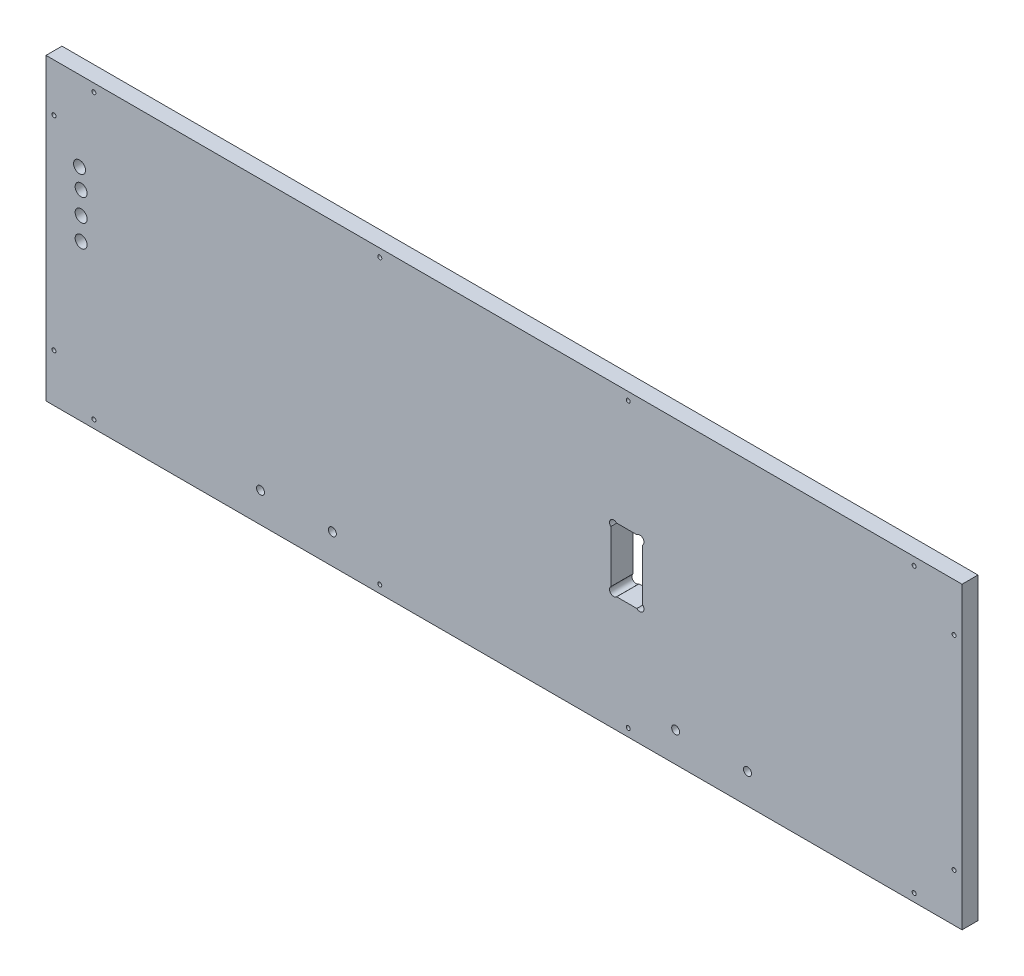
from build123d import *

# Parameters (mm, degrees)
SKETCH2_W          = 728.6625
SKETCH2_H          = 238.125
EXTRUDE1_DEPTH     = 17.78
SKETCH3_R          = 1.5875
SKETCH3_R_2        = 3.175
SKETCH3_W          = 25.4
SKETCH3_H          = 50.8
CUT_EXTRUDE1_DEPTH = 17.78
SKETCH6_R          = 3.302
CUT_EXTRUDE4_DEPTH = 17.78
SKETCH4_W          = 169.8625
SKETCH4_H          = 8.255
CUT_EXTRUDE2_DEPTH = 3.175
CUT_EXTRUDE3_DEPTH = 5.08
SKETCH7_R          = 3.302
CUT_EXTRUDE5_DEPTH = 5.08
SKETCH8_R          = 4.7625
CUT_EXTRUDE6_DEPTH = 17.78


with BuildPart() as part:
    # Sketch2 → Extrude1 (new body)
    with BuildSketch(Plane.XY):
        with Locations((-5376.06875, 779.4625)):
            Rectangle(SKETCH2_W, SKETCH2_H)
    extrude(amount=-EXTRUDE1_DEPTH)

    # Sketch3 → Cut-Extrude1 (cut)
    with BuildSketch(Plane.XY):
        with Locations((-5702.3, 892.175)):
            Circle(SKETCH3_R)
        with Locations((-5734.05, 860.425)):
            Circle(SKETCH3_R)
        with Locations((-5734.05, 698.5)):
            Circle(SKETCH3_R)
        with Locations((-5702.3, 666.75)):
            Circle(SKETCH3_R)
        with Locations((-5569.74375, 684.2125)):
            Circle(SKETCH3_R_2)
        with Locations((-5512.59375, 684.2125)):
            Circle(SKETCH3_R_2)
        with Locations((-5474.890625, 666.75)):
            Circle(SKETCH3_R)
        with Locations((-5277.246875, 666.75)):
            Circle(SKETCH3_R)
        with Locations((-5239.54375, 684.2125)):
            Circle(SKETCH3_R_2)
        with Locations((-5182.39375, 684.2125)):
            Circle(SKETCH3_R_2)
        with Locations((-5049.8375, 666.75)):
            Circle(SKETCH3_R)
        with Locations((-5018.0875, 698.5)):
            Circle(SKETCH3_R)
        with Locations((-5018.0875, 860.425)):
            Circle(SKETCH3_R)
        with Locations((-5049.8375, 892.175)):
            Circle(SKETCH3_R)
        with Locations((-5277.246875, 892.175)):
            Circle(SKETCH3_R)
        with Locations((-5474.890625, 892.175)):
            Circle(SKETCH3_R)
        with Locations((-5278.4375, 777.875)):
            Rectangle(SKETCH3_W, SKETCH3_H)
    extrude(amount=-CUT_EXTRUDE1_DEPTH, mode=Mode.SUBTRACT)

    # Sketch6 → Cut-Extrude4 (cut)
    with BuildSketch(Plane.XY):
        with Locations((-5288.802633409, 800.940133409)):
            Circle(SKETCH6_R)
        with Locations((-5268.072366591, 800.940133409)):
            Circle(SKETCH6_R)
        with Locations((-5288.802633409, 754.809866591)):
            Circle(SKETCH6_R)
        with Locations((-5268.072366591, 754.809866591)):
            Circle(SKETCH6_R)
    extrude(amount=-CUT_EXTRUDE4_DEPTH, mode=Mode.SUBTRACT)

    # Sketch4 → Cut-Extrude2 (cut)
    with BuildSketch(Plane.XZ.offset(-660.4)):
        with Locations((-5376.06875, -13.6525)):
            Rectangle(SKETCH4_W, SKETCH4_H)
    extrude(amount=-CUT_EXTRUDE2_DEPTH, mode=Mode.SUBTRACT)

    # Sketch5 → Cut-Extrude3 (cut)
    with BuildSketch(Plane(origin=(0, 0, -17.78), x_dir=(-1, 0, 0), z_dir=(0, 0, -1))):
        Polygon((5011.7375, 660.4), (5113.3375, 660.4), (5113.3375, 673.1), (5024.4375, 673.1), (5024.4375, 885.825), (5727.7, 885.825), (5727.7, 673.1), (5638.8, 673.1), (5638.8, 660.4), (5740.4, 660.4), (5740.4, 898.525), (5011.7375, 898.525), align=None)
    extrude(amount=-CUT_EXTRUDE3_DEPTH, mode=Mode.SUBTRACT)

    # Sketch7 → Cut-Extrude5 (cut)
    with BuildSketch(Plane(origin=(0, 0, -17.78), x_dir=(-1, 0, 0), z_dir=(0, 0, -1))):
        with Locations((5641.525003649, 671.235178531)):
            Circle(SKETCH7_R)
        with Locations((5110.612496351, 671.235178531)):
            Circle(SKETCH7_R)
    extrude(amount=-CUT_EXTRUDE5_DEPTH, mode=Mode.SUBTRACT)

    # Sketch8 → Cut-Extrude6 (cut)
    with BuildSketch(Plane(origin=(0, 0, -17.78), x_dir=(-1, 0, 0), z_dir=(0, 0, -1))):
        with Locations((5713.73, 835.025)):
            Circle(SKETCH8_R)
        with Locations((5712.46, 819.785)):
            Circle(SKETCH8_R)
        with Locations((5712.46, 802.005)):
            Circle(SKETCH8_R)
        with Locations((5712.46, 784.225)):
            Circle(SKETCH8_R)
    extrude(amount=-CUT_EXTRUDE6_DEPTH, mode=Mode.SUBTRACT)


solid = part.part
